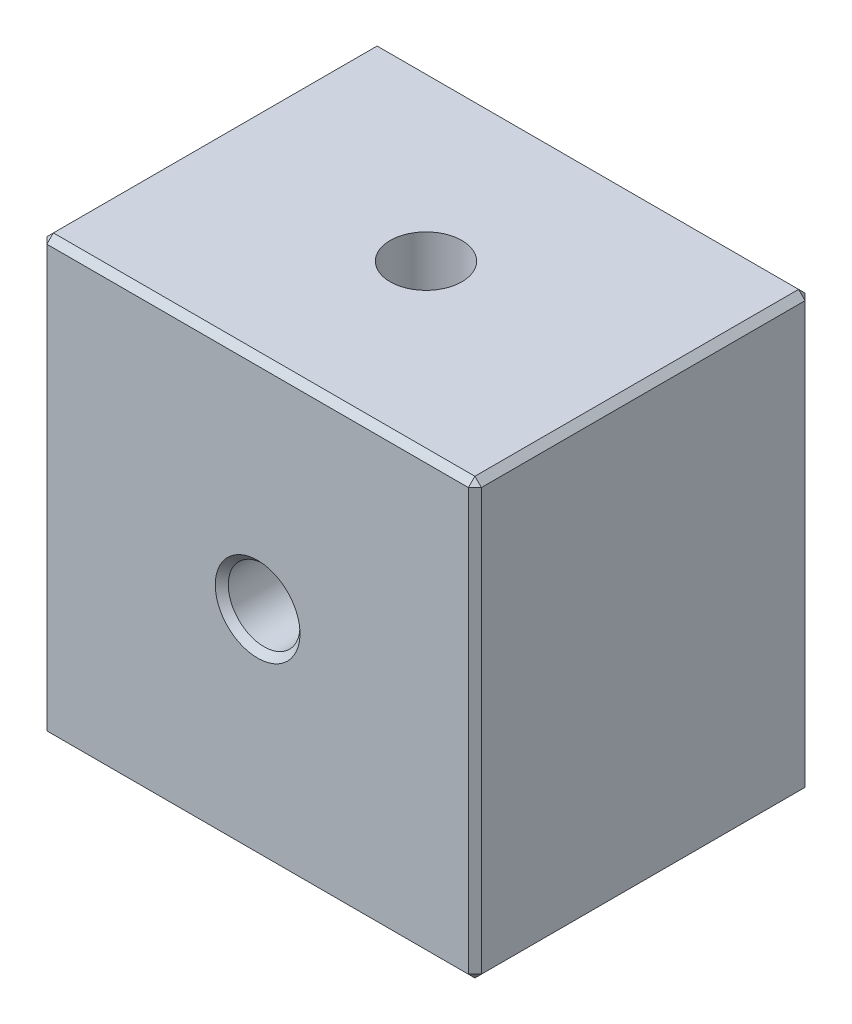
from build123d import *

# Parameters (mm, degrees)
SKETCH_1_W         = 20
SKETCH_1_H         = 20
EXTRUDE_1_DEPTH    = 7.75
HOLE_WIZARD_M4_1_D = 3.3
HOLE_WIZARD_M4_2_D = 3.3
CHAMFER_1_SIZE     = 0.3


with BuildPart() as part:
    # 草图1 → 凸台-拉伸1 (new body, symmetric)
    with BuildSketch(Plane.XY):
        Rectangle(SKETCH_1_W, SKETCH_1_H)
    extrude(amount=EXTRUDE_1_DEPTH, both=True)

    # M4 螺纹孔1 (through all)
    with Locations(Plane.XY.offset(7.75)):
        with Locations((0, 0)):
            Hole(HOLE_WIZARD_M4_1_D / 2)

    # M4 螺纹孔2 (through all)
    with Locations(Plane(origin=(0, 10, 0), x_dir=(1, 0, 0), z_dir=(0, 1, 0))):
        with Locations((0, 0)):
            Hole(HOLE_WIZARD_M4_2_D / 2)

    # 倒角1
    chamfer_1_edges = [part.edges().sort_by_distance(p)[0] for p in [
        (-10, 0, 7.75),
        (1.65, 0, 7.75),
        (0, -10, 7.75),
        (10, 0, 7.75),
        (0, -10, -7.75),
        (-10, 0, -7.75),
        (0, 10, -7.75),
        (10, 0, -7.75),
        (10, -10, 0),
        (-10, -10, 0),
        (-10, 10, 0),
        (10, 10, 0),
        (0, 10, 7.75),
    ]]
    chamfer(chamfer_1_edges, length=CHAMFER_1_SIZE)


solid = part.part
